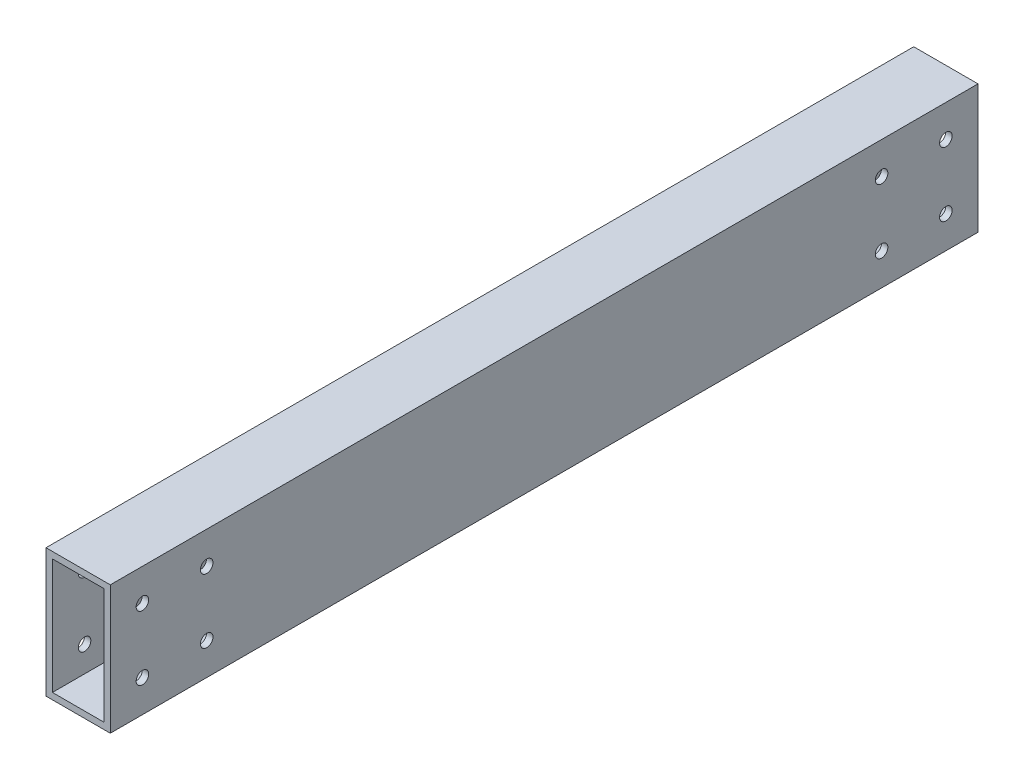
from build123d import *

# Parameters (mm, degrees)
SKETCH1_W               = 25.4
SKETCH1_H               = 50.8
SKETCH1_W_2             = 20.32
SKETCH1_H_2             = 45.72
EXTRUDE_THIN1_DEPTH     = 171.45
SKETCH2_R               = 2.4765
CUT_EXTRUDE1_DEPTH      = 13.7
CUT_EXTRUDE1_DEPTH_BACK = 13.7


with BuildPart() as part:
    # Sketch1 → Extrude-Thin1 (new body, symmetric)
    with BuildSketch(Plane.XY):
        Rectangle(SKETCH1_W, SKETCH1_H)
        Rectangle(SKETCH1_W_2, SKETCH1_H_2, mode=Mode.SUBTRACT)
    extrude(amount=EXTRUDE_THIN1_DEPTH, both=True)

    # Sketch2 → Cut-Extrude1 (cut, two sides)
    with BuildSketch(Plane(origin=(0, 0, 0), x_dir=(0, 0, -1), z_dir=(1, 0, 0))) as cut_extrude1_sk:
        with Locations((133.35, 12.7)):
            Circle(SKETCH2_R)
        with Locations((133.35, -12.7)):
            Circle(SKETCH2_R)
        with Locations((158.75, -12.7)):
            Circle(SKETCH2_R)
        with Locations((158.75, 12.7)):
            Circle(SKETCH2_R)
        with Locations((-133.35, 12.7)):
            Circle(SKETCH2_R)
        with Locations((-158.75, 12.7)):
            Circle(SKETCH2_R)
        with Locations((-158.75, -12.7)):
            Circle(SKETCH2_R)
        with Locations((-133.35, -12.7)):
            Circle(SKETCH2_R)
    extrude(amount=CUT_EXTRUDE1_DEPTH, mode=Mode.SUBTRACT)
    extrude(cut_extrude1_sk.sketch, amount=-CUT_EXTRUDE1_DEPTH_BACK, mode=Mode.SUBTRACT)


solid = part.part
